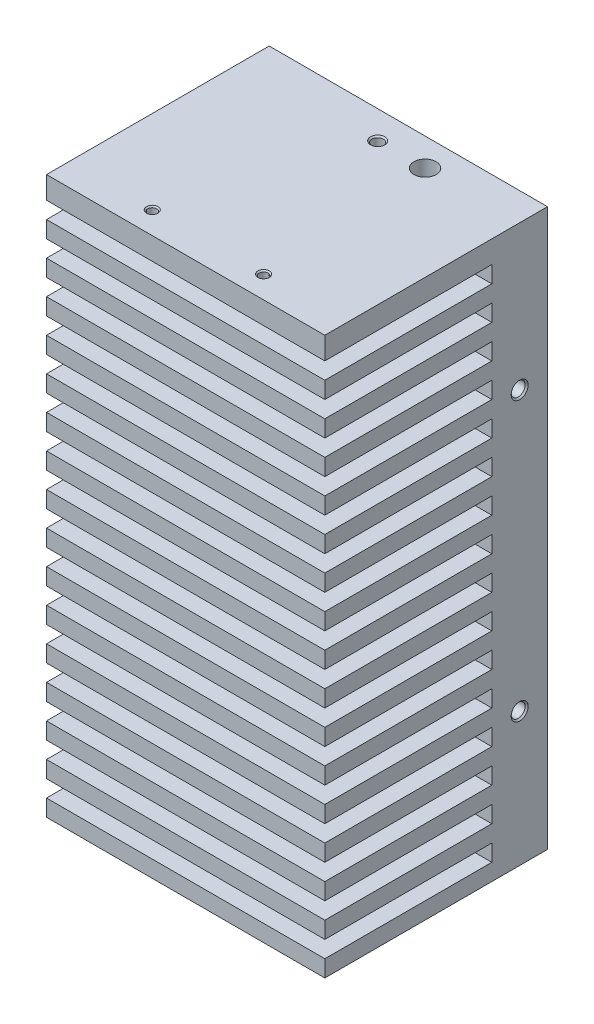
from build123d import *

# Parameters (mm, degrees)
SKETCH2_W                     = 50
SKETCH2_H                     = 100
BOSS_EXTRUDE1_DEPTH           = 40
M3_TAPPED_HOLE2_D             = 2.5
M3_TAPPED_HOLE2_DEPTH         = 10
M3_TAPPED_HOLE2_CSINK_D       = 3.05
M3_TAPPED_HOLE2_CSINK_ANGLE   = 90
M3_TAPPED_HOLE2_TIP           = 0.751075774
M2_TAPPED_HOLE1_AT_2_COUNT    = 2
M2_TAPPED_HOLE1_AT_2_PITCH    = 15.945218719
LPATTERN1_COUNT               = 3
LPATTERN1_PITCH               = 30
SKETCH6_R                     = 2
CUT_EXTRUDE4_DEPTH            = 25
M2_5_TAPPED_HOLE1_D           = 2.05
M2_5_TAPPED_HOLE1_DEPTH       = 10
M2_5_TAPPED_HOLE1_CSINK_D     = 2.55
M2_5_TAPPED_HOLE1_CSINK_ANGLE = 90
M2_5_TAPPED_HOLE1_TIP         = 0.615882135
SKETCH8_W                     = 30
SKETCH8_H                     = 3
CUT_EXTRUDE6_DEPTH            = 51
M2_TAPPED_HOLE2_D             = 1.6
M2_TAPPED_HOLE2_DEPTH         = 10
M2_TAPPED_HOLE2_CSINK_D       = 2.05
M2_TAPPED_HOLE2_CSINK_ANGLE   = 90
M2_TAPPED_HOLE2_TIP           = 0.480688495
M2_TAPPED_HOLE3_D             = 1.6
M2_TAPPED_HOLE3_DEPTH         = 10
M2_TAPPED_HOLE3_CSINK_D       = 2.05
M2_TAPPED_HOLE3_CSINK_ANGLE   = 90
M2_TAPPED_HOLE3_TIP           = 0.480688495


with BuildPart() as part:
    # Sketch2 → Boss-Extrude1 (new body)
    with BuildSketch(Plane.XY):
        with Locations((25, 50)):
            Rectangle(SKETCH2_W, SKETCH2_H)
    extrude(amount=BOSS_EXTRUDE1_DEPTH)

    # M3 Tapped Hole2
    with Locations(Plane(origin=(50, 0, 0), x_dir=(0, 0, -1), z_dir=(1, 0, 0))):
        with Locations((-5, 74), (-5, 24)):
            CounterSinkHole(M3_TAPPED_HOLE2_D / 2, M3_TAPPED_HOLE2_CSINK_D / 2, depth=M3_TAPPED_HOLE2_DEPTH, counter_sink_angle=M3_TAPPED_HOLE2_CSINK_ANGLE)
            with Locations((0, 0, -(M3_TAPPED_HOLE2_DEPTH + M3_TAPPED_HOLE2_TIP / 2))):  # 118° drill point
                Cone(0, M3_TAPPED_HOLE2_D / 2, M3_TAPPED_HOLE2_TIP, mode=Mode.SUBTRACT)

    # Sketch12 → M2 Tapped Hole1 (revolve, cut)
    with BuildSketch(Plane(origin=(26.8, 25.25, 0), x_dir=(0, 1, 0), z_dir=(1, 0, 0))):
        Polygon((0, 0), (0, 10.480688495), (0.8, 10), (0.8, 0.225), (1.025, 0), align=None)
    m2_tapped_hole1 = revolve(axis=Axis((26.8, 25.25, -6.35), (0, 0, 1)), mode=Mode.SUBTRACT)

    # M2 Tapped Hole1 at 2: M2 Tapped Hole1 ×2
    with Locations(*[Vector(-0.752576695, -0.658504608, 0) * (i * M2_TAPPED_HOLE1_AT_2_PITCH) for i in range(1, M2_TAPPED_HOLE1_AT_2_COUNT)]):
        add(m2_tapped_hole1, mode=Mode.SUBTRACT)

    # LPattern1: M2 Tapped Hole1 ×3
    with Locations(*[(0, i * LPATTERN1_PITCH, 0) for i in range(1, LPATTERN1_COUNT)]):
        add(m2_tapped_hole1, mode=Mode.SUBTRACT)

    # LPattern1 copy 1 sketch → LPattern1 copy 1 (revolve, cut)
    with BuildSketch(Plane(origin=(14.8, 44.75, 0), x_dir=(0, 1, 0), z_dir=(1, 0, 0))):
        Polygon((0, 0), (0, 10.480688495), (0.8, 10), (0.8, 0.225), (1.025, 0), align=None)
    revolve(axis=Axis((14.8, 44.75, -6.35), (0, 0, 1)), mode=Mode.SUBTRACT)

    # LPattern1 copy 2 sketch → LPattern1 copy 2 (revolve, cut)
    with BuildSketch(Plane(origin=(14.8, 74.75, 0), x_dir=(0, 1, 0), z_dir=(1, 0, 0))):
        Polygon((0, 0), (0, 10.480688495), (0.8, 10), (0.8, 0.225), (1.025, 0), align=None)
    revolve(axis=Axis((14.8, 74.75, -6.35), (0, 0, 1)), mode=Mode.SUBTRACT)

    # Sketch6 → Cut-Extrude4 (cut)
    with BuildSketch(Plane(origin=(0, 100, 0), x_dir=(1, 0, 0), z_dir=(0, 1, 0))):
        with Locations((33, -5)):
            Circle(SKETCH6_R)
    extrude(amount=-CUT_EXTRUDE4_DEPTH, mode=Mode.SUBTRACT)

    # M2.5 Tapped Hole1
    with Locations(Plane(origin=(0, 100, 0), x_dir=(1, 0, 0), z_dir=(0, 1, 0))):
        with Locations((24.5, -5)):
            CounterSinkHole(M2_5_TAPPED_HOLE1_D / 2, M2_5_TAPPED_HOLE1_CSINK_D / 2, depth=M2_5_TAPPED_HOLE1_DEPTH, counter_sink_angle=M2_5_TAPPED_HOLE1_CSINK_ANGLE)
            with Locations((0, 0, -(M2_5_TAPPED_HOLE1_DEPTH + M2_5_TAPPED_HOLE1_TIP / 2))):  # 118° drill point
                Cone(0, M2_5_TAPPED_HOLE1_D / 2, M2_5_TAPPED_HOLE1_TIP, mode=Mode.SUBTRACT)

    # Sketch8 → Cut-Extrude6 (cut, through all)
    with BuildSketch(Plane(origin=(50, 0, 0), x_dir=(0, 0, -1), z_dir=(1, 0, 0))):
        with Locations((-25, 4.5)):
            Rectangle(SKETCH8_W, SKETCH8_H)
        with Locations((-25, 10.5)):
            Rectangle(SKETCH8_W, SKETCH8_H)
        with Locations((-25, 16.5)):
            Rectangle(SKETCH8_W, SKETCH8_H)
        with Locations((-25, 22.5)):
            Rectangle(SKETCH8_W, SKETCH8_H)
        with Locations((-25, 28.5)):
            Rectangle(SKETCH8_W, SKETCH8_H)
        with Locations((-25, 34.5)):
            Rectangle(SKETCH8_W, SKETCH8_H)
        with Locations((-25, 40.5)):
            Rectangle(SKETCH8_W, SKETCH8_H)
        with Locations((-25, 46.5)):
            Rectangle(SKETCH8_W, SKETCH8_H)
        with Locations((-25, 52.5)):
            Rectangle(SKETCH8_W, SKETCH8_H)
        with Locations((-25, 58.5)):
            Rectangle(SKETCH8_W, SKETCH8_H)
        with Locations((-25, 64.5)):
            Rectangle(SKETCH8_W, SKETCH8_H)
        with Locations((-25, 70.5)):
            Rectangle(SKETCH8_W, SKETCH8_H)
        with Locations((-25, 76.5)):
            Rectangle(SKETCH8_W, SKETCH8_H)
        with Locations((-25, 82.5)):
            Rectangle(SKETCH8_W, SKETCH8_H)
        with Locations((-25, 88.5)):
            Rectangle(SKETCH8_W, SKETCH8_H)
        with Locations((-25, 94.5)):
            Rectangle(SKETCH8_W, SKETCH8_H)
    extrude(amount=-CUT_EXTRUDE6_DEPTH, mode=Mode.SUBTRACT)

    # M2 Tapped Hole2
    with Locations(Plane(origin=(0, 100, 0), x_dir=(1, 0, 0), z_dir=(0, 1, 0))):
        with Locations((15, -36), (35, -36)):
            CounterSinkHole(M2_TAPPED_HOLE2_D / 2, M2_TAPPED_HOLE2_CSINK_D / 2, depth=M2_TAPPED_HOLE2_DEPTH, counter_sink_angle=M2_TAPPED_HOLE2_CSINK_ANGLE)
            with Locations((0, 0, -(M2_TAPPED_HOLE2_DEPTH + M2_TAPPED_HOLE2_TIP / 2))):  # 118° drill point
                Cone(0, M2_TAPPED_HOLE2_D / 2, M2_TAPPED_HOLE2_TIP, mode=Mode.SUBTRACT)

    # M2 Tapped Hole3
    with Locations(Plane(origin=(0, 0, 0), x_dir=(-1, 0, 0), z_dir=(0, -1, 0))):
        with Locations((-15, -36), (-35, -36)):
            CounterSinkHole(M2_TAPPED_HOLE3_D / 2, M2_TAPPED_HOLE3_CSINK_D / 2, depth=M2_TAPPED_HOLE3_DEPTH, counter_sink_angle=M2_TAPPED_HOLE3_CSINK_ANGLE)
            with Locations((0, 0, -(M2_TAPPED_HOLE3_DEPTH + M2_TAPPED_HOLE3_TIP / 2))):  # 118° drill point
                Cone(0, M2_TAPPED_HOLE3_D / 2, M2_TAPPED_HOLE3_TIP, mode=Mode.SUBTRACT)


solid = part.part
